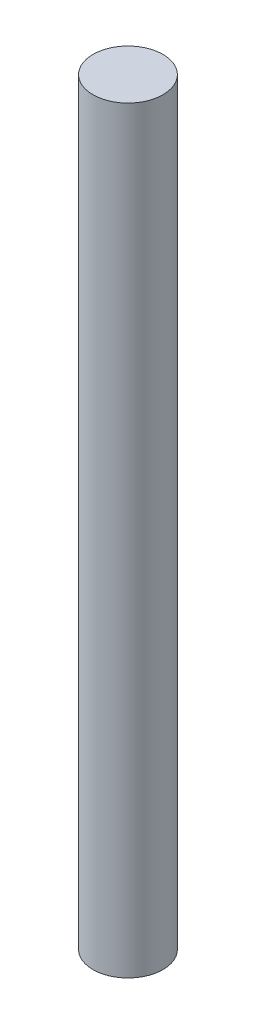
from build123d import *

# Parameters (mm, degrees)
SKETCH1_R           = 3
BOSS_EXTRUDE1_DEPTH = 65


with BuildPart() as part:
    # Sketch1 → Boss-Extrude1 (new body)
    with BuildSketch(Plane(origin=(0, 0, 0), x_dir=(1, 0, 0), z_dir=(0, 1, 0))):
        Circle(SKETCH1_R)
    extrude(amount=BOSS_EXTRUDE1_DEPTH)


solid = part.part
